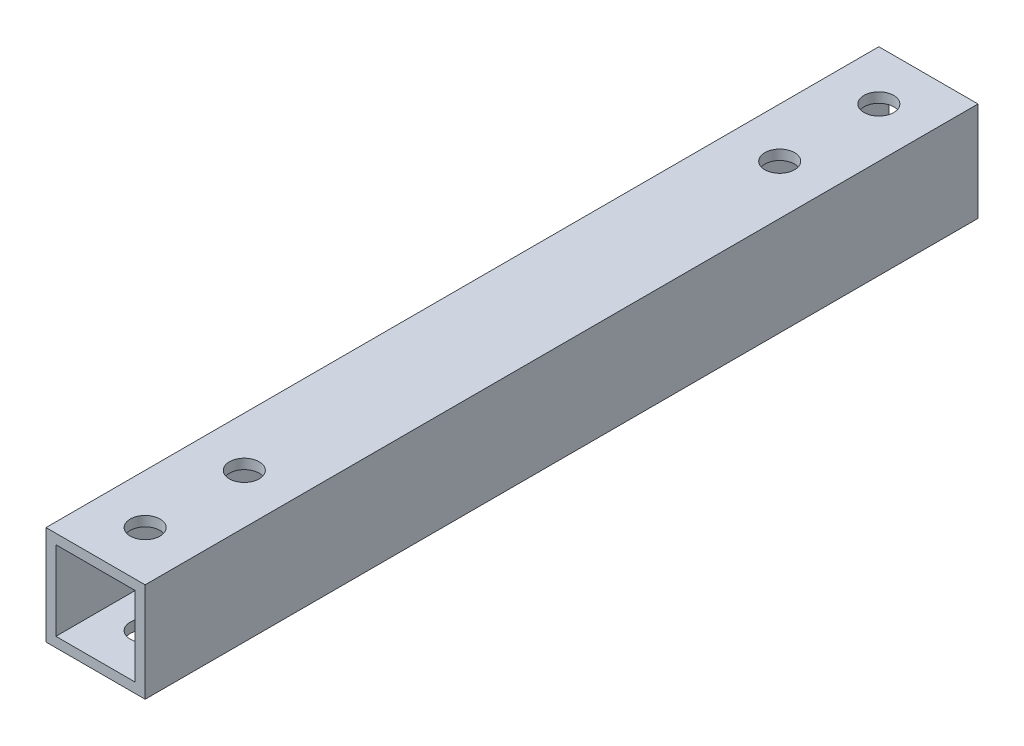
from build123d import *

# Parameters (mm, degrees)
SKETCH_1_W          = 10
SKETCH_1_H          = 10
SKETCH_1_W_2        = 8
SKETCH_1_H_2        = 8
EXTRUDE_1_DEPTH     = 84
SKETCH_3_R          = 1.5
CUT_EXTRUDE_2_DEPTH = 10


with BuildPart() as part:
    # 草图1 → 拉伸-薄壁1 (new body)
    with BuildSketch(Plane.XY):
        with Locations((-72.076665045, -5)):
            Rectangle(SKETCH_1_W, SKETCH_1_H)
        with Locations((-72.076665045, -5)):
            Rectangle(SKETCH_1_W_2, SKETCH_1_H_2, mode=Mode.SUBTRACT)
    extrude(amount=EXTRUDE_1_DEPTH)

    # 草图3 → 切除-拉伸2 (cut)
    with BuildSketch(Plane.XZ.offset(10)):
        with Locations((-72.076665045, 5)):
            Circle(SKETCH_3_R)
        with Locations((-72.076665045, 79)):
            Circle(SKETCH_3_R)
        with Locations((-72.076665045, 69)):
            Circle(SKETCH_3_R)
        with Locations((-72.076665045, 15)):
            Circle(SKETCH_3_R)
    extrude(amount=-CUT_EXTRUDE_2_DEPTH, mode=Mode.SUBTRACT)


solid = part.part
